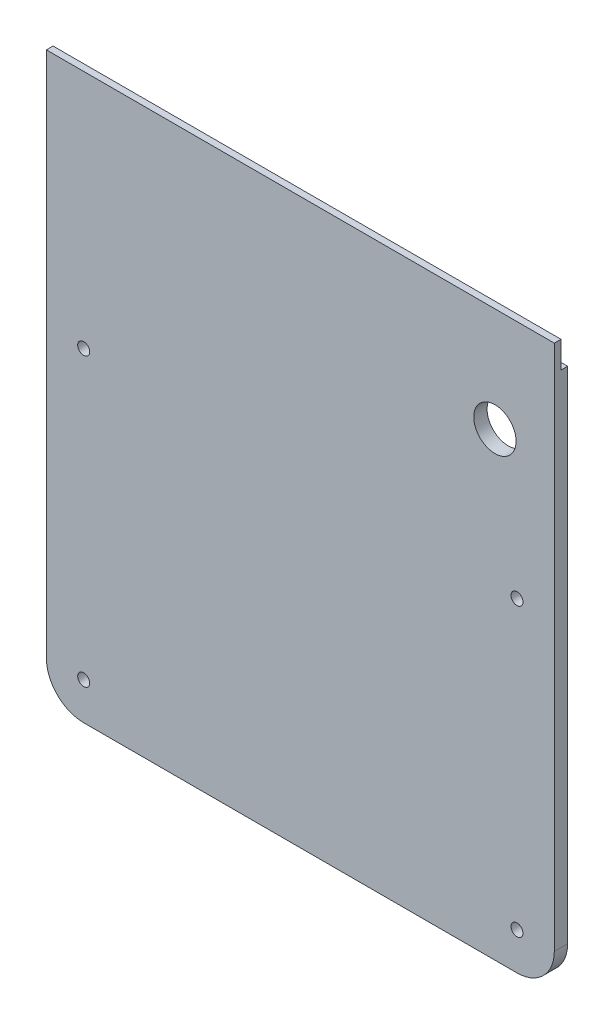
from build123d import *

# Parameters (mm, degrees)
SKETCH4_R           = 2.25
SKETCH4_R_2         = 7.9375
BOSS_EXTRUDE1_DEPTH = 5
CUT_EXTRUDE1_DEPTH  = 191.5


with BuildPart() as part:
    # Sketch4 → Boss-Extrude1 (new body)
    with BuildSketch(Plane.XY):
        with BuildLine():
            Line((-66.080112923, -1201.56262), (96.419887077, -1201.56262))
            ThreePointArc((96.419887077, -1201.56262), (106.319382013, -1197.462114937), (110.419887077, -1187.56262))
            Line((110.419887077, -1187.56262), (110.419887077, -812.43738))
            ThreePointArc((110.419887077, -812.43738), (106.319382013, -802.537885063), (96.419887077, -798.43738))
            Line((96.419887077, -798.43738), (-66.080112923, -798.43738))
            ThreePointArc((-66.080112923, -798.43738), (-75.97960786, -802.537885063), (-80.080112923, -812.43738))
            Line((-80.080112923, -812.43738), (-80.080112923, -1187.56262))
            ThreePointArc((-80.080112923, -1187.56262), (-75.97960786, -1197.462114937), (-66.080112923, -1201.56262))
        make_face()
        with Locations((96.419887077, -1080)):
            Circle(SKETCH4_R, mode=Mode.SUBTRACT)
        with Locations((88.147808187, -1029.0799835)):
            Circle(SKETCH4_R_2, mode=Mode.SUBTRACT)
        with Locations((-66.080112923, -1080)):
            Circle(SKETCH4_R, mode=Mode.SUBTRACT)
        with Locations((96.419887077, -920)):
            Circle(SKETCH4_R, mode=Mode.SUBTRACT)
        with Locations((-66.080112923, -920)):
            Circle(SKETCH4_R, mode=Mode.SUBTRACT)
        with Locations((-66.080112923, -1187.56262)):
            Circle(SKETCH4_R, mode=Mode.SUBTRACT)
        with Locations((96.419887077, -1187.56262)):
            Circle(SKETCH4_R, mode=Mode.SUBTRACT)
        with Locations((-66.080112923, -812.43738)):
            Circle(SKETCH4_R, mode=Mode.SUBTRACT)
        with Locations((96.419887077, -812.43738)):
            Circle(SKETCH4_R, mode=Mode.SUBTRACT)
    extrude(amount=BOSS_EXTRUDE1_DEPTH)

    # Sketch6 → Cut-Extrude1 (cut, through all)
    with BuildSketch(Plane(origin=(110.419887077, 0, 0), x_dir=(0, 0, -1), z_dir=(1, 0, 0))):
        Polygon((-5, -990), (-2.5, -990), (-2.5, -1000), (0, -1000), (102.688211321, -812.43738), (-56.641520251, -690.463913443), (-113.62806658, -898.225606144), align=None)
    extrude(amount=-CUT_EXTRUDE1_DEPTH, mode=Mode.SUBTRACT)


solid = part.part
